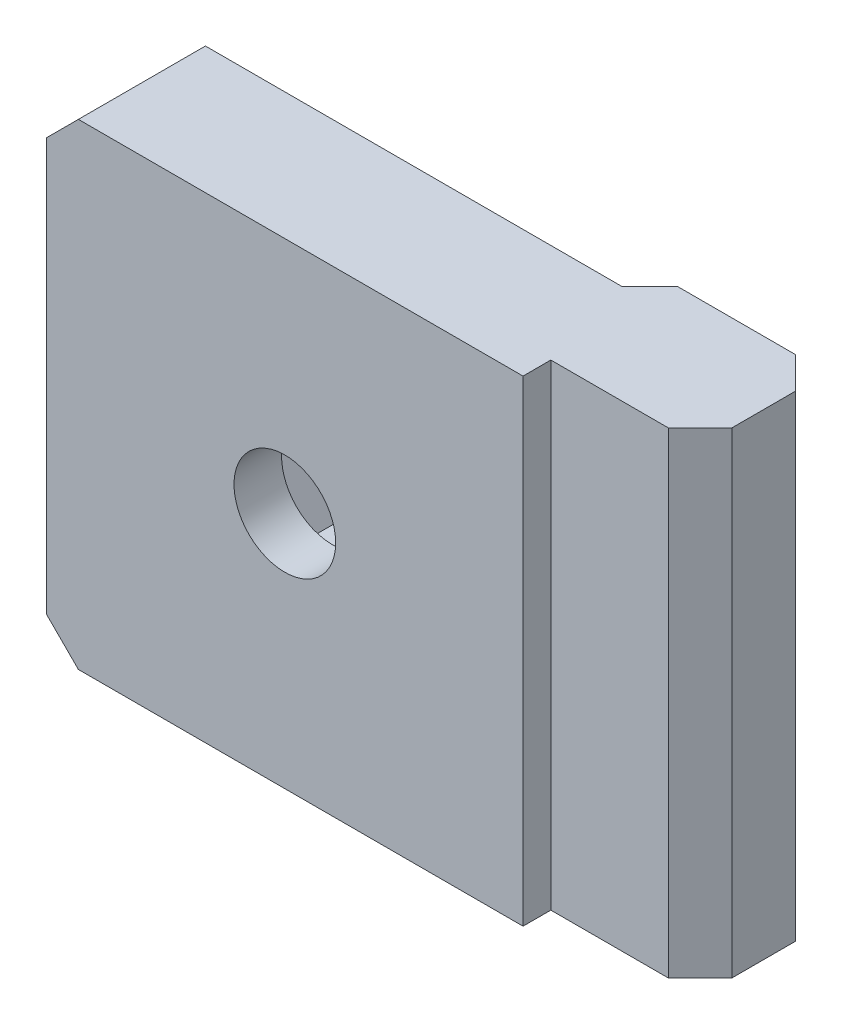
from build123d import *

# Parameters (mm, degrees)
SALIENTE_EXTRUIR1_DEPTH = 15
CROQUIS2_R              = 3.2
CORTAR_EXTRUIR1_DEPTH   = 10.75
CORTAR_EXTRUIR2_START   = -3
CORTAR_EXTRUIR2_DEPTH   = 7.75
CHAFL_N1_SIZE           = 2


with BuildPart() as part:
    # Croquis1 → Saliente-Extruir1 (new body, symmetric)
    with BuildSketch(Plane(origin=(0, 0, 0), x_dir=(1, 0, 0), z_dir=(0, 1, 0))):
        Polygon((0, 0), (-30, 0), (-30, 8), (-1.75, 8), (0, 9.75), (9.4, 9.75), (9.4, 1.75), (0, 1.75), align=None)
    extrude(amount=SALIENTE_EXTRUIR1_DEPTH, both=True)

    # Croquis2 → Cortar-Extruir1 (cut, through all)
    with BuildSketch(Plane.XY):
        with Locations((-15, 0)):
            Circle(CROQUIS2_R)
    extrude(amount=-CORTAR_EXTRUIR1_DEPTH, mode=Mode.SUBTRACT)

    # Croquis3 → Cortar-Extruir2 (cut, through all)
    with BuildSketch(Plane.XY.offset(CORTAR_EXTRUIR2_START)):
        Polygon((-9.226497308, 0), (-12.113248654, 5), (-17.886751346, 5), (-20.773502692, 0), (-17.886751346, -5), (-12.113248654, -5), align=None)
    extrude(amount=-CORTAR_EXTRUIR2_DEPTH, mode=Mode.SUBTRACT)

    # Chaflán1
    chafl_n1_edges = [part.edges().sort_by_distance(p)[0] for p in [
        (9.4, 0, -9.75),
        (9.4, 0, -1.75),
        (-30, 15, -4),
        (-30, -15, -4),
    ]]
    chamfer(chafl_n1_edges, length=CHAFL_N1_SIZE)


solid = part.part
